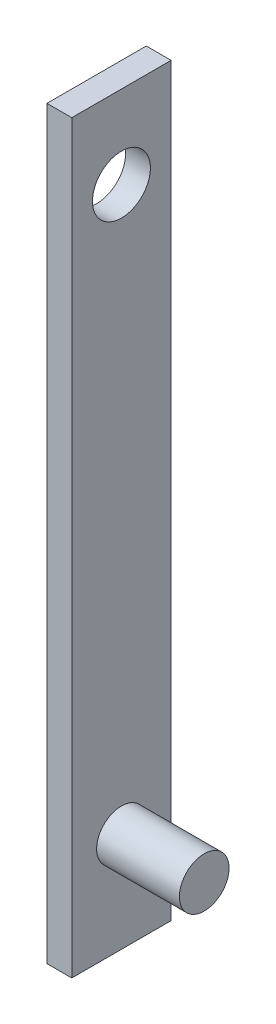
from build123d import *

# Parameters (mm, degrees)
SKETCH1_W           = 12
SKETCH1_H           = 90
BOSS_EXTRUDE1_DEPTH = 3
SKETCH2_R           = 3.5
CUT_EXTRUDE1_DEPTH  = 3
SKETCH3_R           = 3
BOSS_EXTRUDE2_DEPTH = 10


with BuildPart() as part:
    # Sketch1 → Boss-Extrude1 (new body)
    with BuildSketch(Plane(origin=(0, 0, 0), x_dir=(0, 0, -1), z_dir=(1, 0, 0))):
        Rectangle(SKETCH1_W, SKETCH1_H)
    extrude(amount=BOSS_EXTRUDE1_DEPTH)

    # Sketch2 → Cut-Extrude1 (cut)
    with BuildSketch(Plane(origin=(3, 0, 0), x_dir=(0, 0, -1), z_dir=(1, 0, 0))):
        with Locations((0, 35)):
            Circle(SKETCH2_R)
    extrude(amount=-CUT_EXTRUDE1_DEPTH, mode=Mode.SUBTRACT)

    # Sketch3 → Boss-Extrude2 (add)
    with BuildSketch(Plane(origin=(3, 0, 0), x_dir=(0, 0, -1), z_dir=(1, 0, 0))):
        with Locations((0, -33)):
            Circle(SKETCH3_R)
    extrude(amount=BOSS_EXTRUDE2_DEPTH)


solid = part.part
